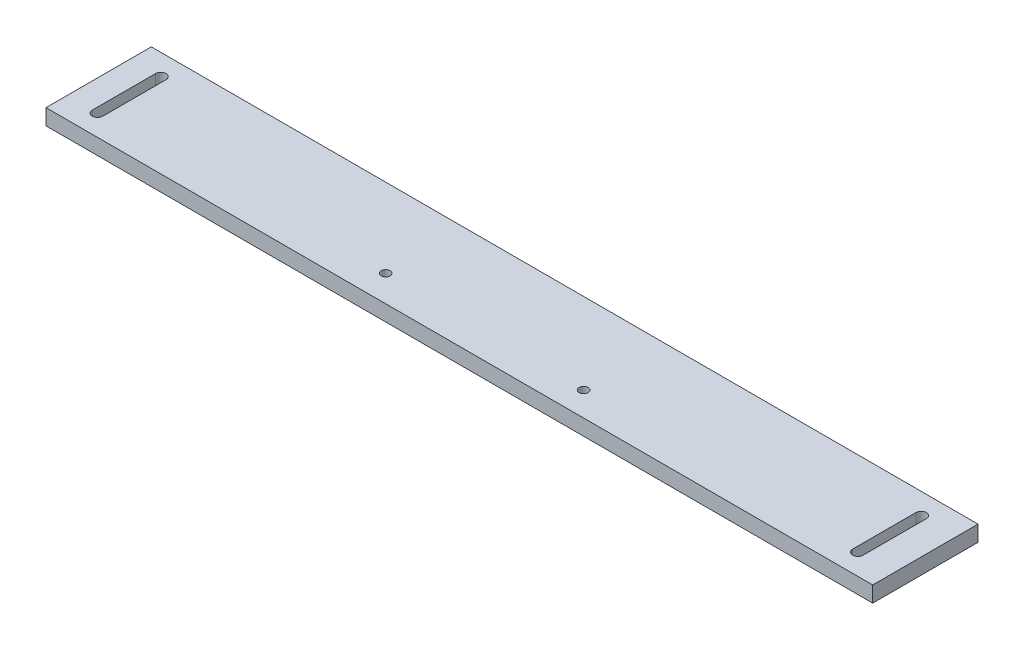
from build123d import *

# Parameters (mm, degrees)
CROQUIS1_W              = 785
CROQUIS1_H              = 100
SALIENTE_EXTRUIR1_DEPTH = 15
CROQUIS5_R              = 4.25
CORTAR_EXTRUIR4_DEPTH   = 16
CORTAR_EXTRUIR5_DEPTH   = 16


with BuildPart() as part:
    # Croquis1 → Saliente-Extruir1 (new body)
    with BuildSketch(Plane(origin=(0, 0, 0), x_dir=(1, 0, 0), z_dir=(0, 1, 0))):
        with Locations((353.936588921, -42.333090379)):
            Rectangle(CROQUIS1_W, CROQUIS1_H)
    extrude(amount=-SALIENTE_EXTRUIR1_DEPTH)

    # Croquis5 → Cortar-Extruir4 (cut, through all)
    with BuildSketch(Plane(origin=(0, 0, 0), x_dir=(1, 0, 0), z_dir=(0, 1, 0))):
        with Locations((258.936588921, -67.333090379)):
            Circle(CROQUIS5_R)
        with Locations((448.92606348, -69.332979585)):
            Circle(CROQUIS5_R)
    extrude(amount=-CORTAR_EXTRUIR4_DEPTH, mode=Mode.SUBTRACT)

    # Croquis6 → Cortar-Extruir5 (cut, through all)
    with BuildSketch(Plane(origin=(0, 0, 0), x_dir=(1, 0, 0), z_dir=(0, 1, 0))):
        with BuildLine():
            Line((717.436588921, -72.333090379), (717.436588921, -12.333090379))
            ThreePointArc((717.436588921, -12.333090379), (712.436588921, -7.333090379), (707.436588921, -12.333090379))
            Line((707.436588921, -12.333090379), (707.436588921, -72.333090379))
            ThreePointArc((707.436588921, -72.333090379), (712.436588921, -77.333090379), (717.436588921, -72.333090379))
        make_face()
        with BuildLine():
            Line((-4.563411079, -12.333090379), (-4.563411079, -72.333090379))
            ThreePointArc((-4.563411079, -72.333090379), (-9.563411079, -77.333090379), (-14.563411079, -72.333090379))
            Line((-14.563411079, -72.333090379), (-14.563411079, -12.333090379))
            ThreePointArc((-14.563411079, -12.333090379), (-9.563411079, -7.333090379), (-4.563411079, -12.333090379))
        make_face()
    extrude(amount=-CORTAR_EXTRUIR5_DEPTH, mode=Mode.SUBTRACT)


solid = part.part
